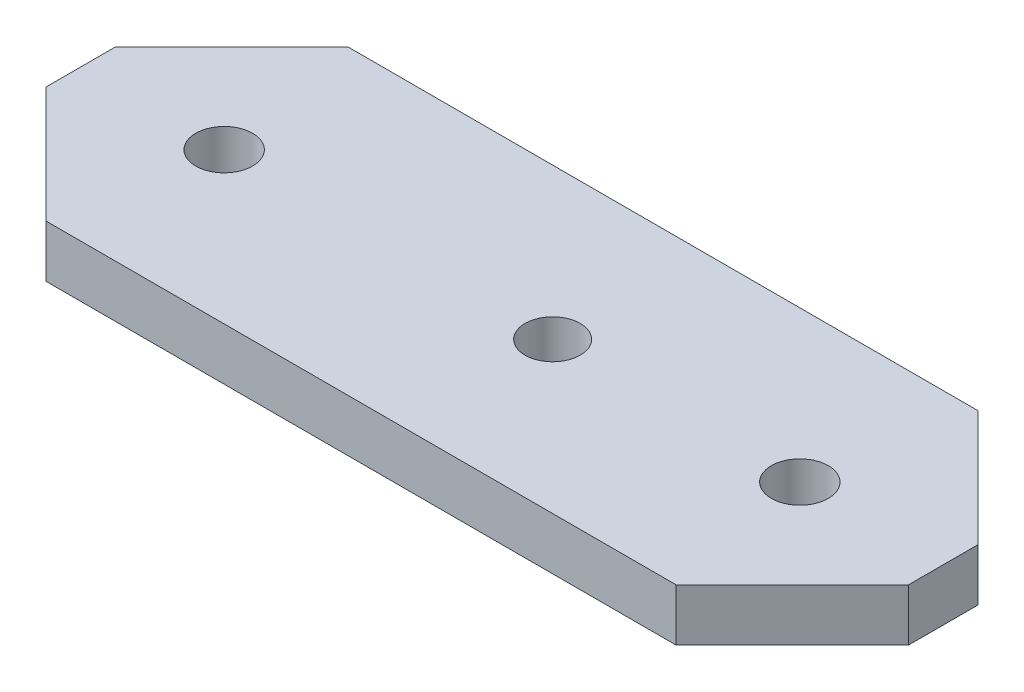
from build123d import *

# Parameters (mm, degrees)
SKETCH1_R           = 2.45
BOSS_EXTRUDE1_DEPTH = 4.5
SKETCH2_R           = 2.375
CUT_EXTRUDE1_DEPTH  = 5.5


with BuildPart() as part:
    # Sketch1 → Boss-Extrude1 (new body)
    with BuildSketch(Plane(origin=(0, 0, 0), x_dir=(1, 0, 0), z_dir=(0, 1, 0))):
        Polygon((27.15, 26), (37.15, 16), (37.15, 10), (27.15, 0), (-27.15, 0), (-37.15, 10), (-37.15, 16), (-27.15, 26), align=None)
        with Locations((24.8, 13)):
            Circle(SKETCH1_R, mode=Mode.SUBTRACT)
        with Locations((-24.8, 13)):
            Circle(SKETCH1_R, mode=Mode.SUBTRACT)
    extrude(amount=BOSS_EXTRUDE1_DEPTH)

    # Sketch2 → Cut-Extrude1 (cut, through all)
    with BuildSketch(Plane(origin=(0, 4.5, 0), x_dir=(1, 0, 0), z_dir=(0, 1, 0))):
        with Locations((3.5, 13)):
            Circle(SKETCH2_R)
    extrude(amount=-CUT_EXTRUDE1_DEPTH, mode=Mode.SUBTRACT)


solid = part.part
